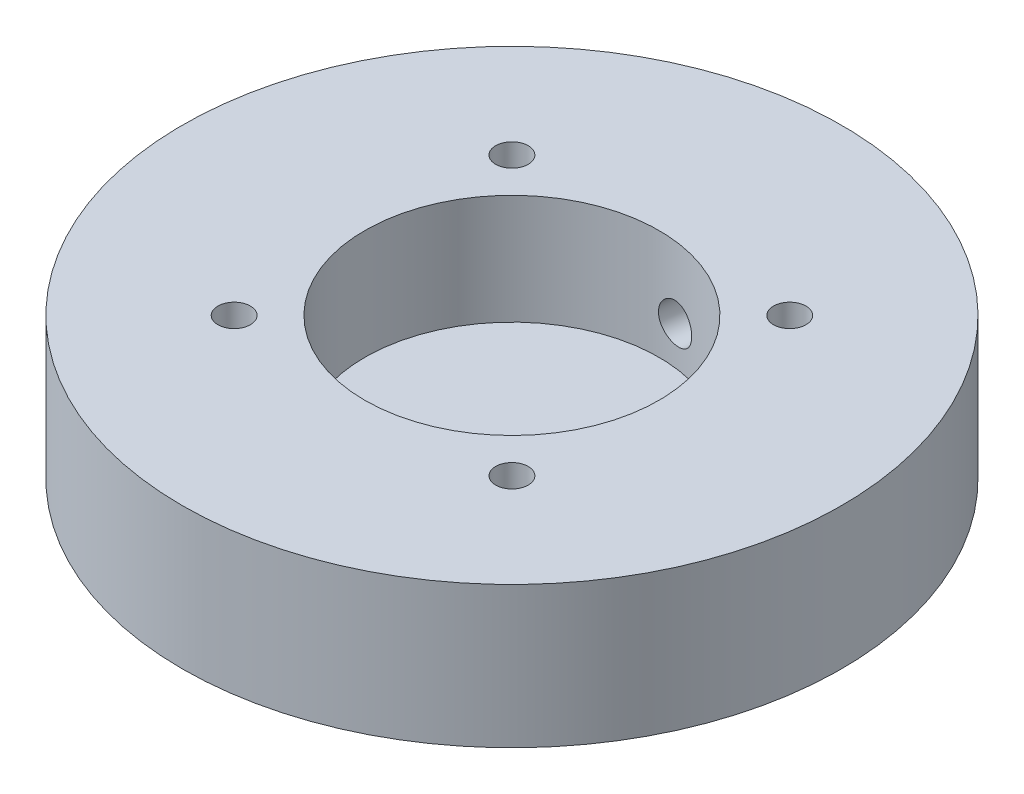
from build123d import *

# Parameters (mm, degrees)
SKETCH2_R                                           = 33.147
BOSS_EXTRUDE1_DEPTH                                 = 14.224
SKETCH4_R                                           = 14.7955
CUT_EXTRUDE1_DEPTH                                  = 11.049
F_24_0_152_DIAMETER_HOLE1_D                         = 3.8608
F_24_0_152_DIAMETER_HOLE1_DEPTH                     = 25.4
F_24_0_152_DIAMETER_HOLE1_TIP                       = 1.159901339
F_24_0_152_DIAMETER_HOLE1_ON_FACE_2_D               = 3.8608
F_24_0_152_DIAMETER_HOLE1_ON_FACE_2_DEPTH           = 25.4
F_24_0_152_DIAMETER_HOLE1_ON_FACE_2_TIP             = 1.159901339
CBORE_FOR_4_BINDING_HEAD_MACHINE_SCREW1_D           = 3.2639
CBORE_FOR_4_BINDING_HEAD_MACHINE_SCREW1_CBORE_D     = 6.74624
CBORE_FOR_4_BINDING_HEAD_MACHINE_SCREW1_CBORE_DEPTH = 11.049


with BuildPart() as part:
    # Sketch2 → Boss-Extrude1 (new body)
    with BuildSketch(Plane(origin=(0, 0, 0), x_dir=(1, 0, 0), z_dir=(0, 1, 0))):
        Circle(SKETCH2_R)
    extrude(amount=BOSS_EXTRUDE1_DEPTH)

    # Sketch4 → Cut-Extrude1 (cut)
    with BuildSketch(Plane(origin=(0, 14.224, 0), x_dir=(1, 0, 0), z_dir=(0, 1, 0))):
        Circle(SKETCH4_R)
    extrude(amount=-CUT_EXTRUDE1_DEPTH, mode=Mode.SUBTRACT)

    # #24 (0.152) Diameter Hole1
    with Locations(Plane(origin=(4.199730969, 7.112, -32.879870267), x_dir=(-0.991941059, 0, -0.126700183), z_dir=(0.126700183, 0, -0.991941059))):
        with Locations((0, 0)):
            Hole(F_24_0_152_DIAMETER_HOLE1_D / 2, depth=F_24_0_152_DIAMETER_HOLE1_DEPTH)
            with Locations((0, 0, -(F_24_0_152_DIAMETER_HOLE1_DEPTH + F_24_0_152_DIAMETER_HOLE1_TIP / 2))):  # 118° drill point
                Cone(0, F_24_0_152_DIAMETER_HOLE1_D / 2, F_24_0_152_DIAMETER_HOLE1_TIP, mode=Mode.SUBTRACT)

    # #24 (0.152) Diameter Hole1 on face 2
    with Locations(Plane(origin=(55.026579736, -11.282884423, 0), x_dir=(-0.991941059, 0, -0.126700183), z_dir=(0.126700183, 0, -0.991941059))):
        with Locations((0, 0)):
            Hole(F_24_0_152_DIAMETER_HOLE1_ON_FACE_2_D / 2, depth=F_24_0_152_DIAMETER_HOLE1_ON_FACE_2_DEPTH)
            with Locations((0, 0, -(F_24_0_152_DIAMETER_HOLE1_ON_FACE_2_DEPTH + F_24_0_152_DIAMETER_HOLE1_ON_FACE_2_TIP / 2))):  # 118° drill point
                Cone(0, F_24_0_152_DIAMETER_HOLE1_ON_FACE_2_D / 2, F_24_0_152_DIAMETER_HOLE1_ON_FACE_2_TIP, mode=Mode.SUBTRACT)

    # CBORE for #4 Binding Head Machine Screw1 (through all)
    with Locations(Plane(origin=(0, 0, 0), x_dir=(-1, 0, 0), z_dir=(0, -1, 0))):
        with Locations((13.97, -13.97), (-13.97, -13.97), (-13.97, 13.97), (13.97, 13.97)):
            CounterBoreHole(CBORE_FOR_4_BINDING_HEAD_MACHINE_SCREW1_D / 2, CBORE_FOR_4_BINDING_HEAD_MACHINE_SCREW1_CBORE_D / 2, CBORE_FOR_4_BINDING_HEAD_MACHINE_SCREW1_CBORE_DEPTH)


solid = part.part
